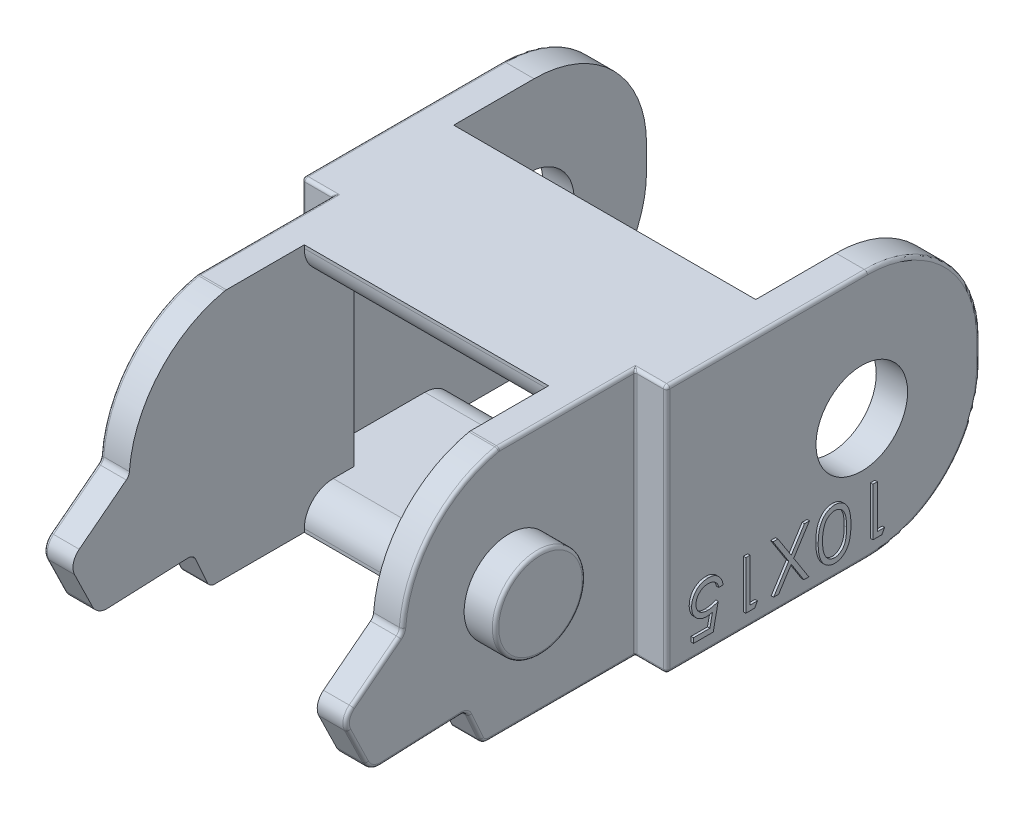
from build123d import *

# Parameters (mm, degrees)
SKETCH1_W               = 38
SKETCH1_H               = 15.5
SKETCH1_R               = 2.85
BOSS_EXTRUDE1_DEPTH     = 11.35
FILLET1_R               = 7
CUT_EXTRUDE1_DEPTH      = 11.35
FILLET2_R               = 1
FILLET3_R               = 0.5
SKETCH4_R               = 2.8
CUT_EXTRUDE2_DEPTH      = 1.95
SKETCH5_W               = 18.8
SKETCH5_H               = 12
SKETCH5_W_2             = 15.2
SKETCH5_H_2             = 14.395243704
CUT_EXTRUDE3_DEPTH      = 8.75
CUT_EXTRUDE3_DEPTH_BACK = 8.75
SKETCH6_W               = 15.2
SKETCH6_H               = 11.5
CUT_EXTRUDE4_DEPTH      = 11.1
CUT_EXTRUDE5_DEPTH      = 11.5
FILLET4_R               = 0.2
BOSS_EXTRUDE2_DEPTH     = 0.15
BOSS_EXTRUDE3_DEPTH     = 0.15
FILLET5_R               = 1.8
FILLET6_R               = 0.2
FILLET7_R               = 0.2
FILLET8_R               = 0.1


with BuildPart() as part:
    # Sketch1 → Boss-Extrude1 (new body, symmetric)
    with BuildSketch(Plane(origin=(0, 0, 0), x_dir=(0, 0, -1), z_dir=(1, 0, 0))):
        with Locations((-11.65, 0)):
            Rectangle(SKETCH1_W, SKETCH1_H)
        Circle(SKETCH1_R, mode=Mode.SUBTRACT)
    extrude(amount=BOSS_EXTRUDE1_DEPTH, both=True)

    # Fillet1
    fillet1_edges = [part.edges().sort_by_distance(p)[0] for p in [
        (0, 7.75, -7.35),
        (0, -7.75, -7.35),
    ]]
    fillet(fillet1_edges, radius=FILLET1_R)

    # Sketch2 → Cut-Extrude1 (cut, symmetric)
    with BuildSketch(Plane(origin=(0, 0, 0), x_dir=(0, 0, -1), z_dir=(1, 0, 0))):
        with BuildLine():
            Line((-26.65, 0.75), (-30.4, -2.153126358))
            Line((-30.4, -2.153126358), (-28.65, -5.75))
            Line((-28.65, -5.75), (-22.655210596, -5.5))
            Line((-22.655210596, -5.5), (-21.65, -7.75))
            Line((-21.65, -7.75), (-30.65, -7.75))
            Line((-30.65, -7.75), (-37.65, -7.75))
            Line((-37.65, -7.75), (-37.65, 7.75))
            Line((-37.65, 7.75), (-30.65, 7.75))
            Line((-30.65, 7.75), (-20.65, 7.75))
            ThreePointArc((-20.65, 7.75), (-24.852601882, 5.280801613), (-26.65, 0.75))
        make_face()
    extrude(amount=CUT_EXTRUDE1_DEPTH, both=True, mode=Mode.SUBTRACT)

    # Fillet2
    fillet2_edges = [part.edges().sort_by_distance(p)[0] for p in [
        (0, -2.153126358, 30.4),
        (0, -5.75, 28.65),
    ]]
    fillet(fillet2_edges, radius=FILLET2_R)

    # Fillet3
    fillet3_edges = [part.edges().sort_by_distance(p)[0] for p in [
        (0, -7.75, 21.65),
        (0, 7.75, 20.65),
        (0, 0.75, 26.65),
        (0, -5.5, 22.655210596),
    ]]
    fillet(fillet3_edges, radius=FILLET3_R)

    # Sketch4 → Cut-Extrude2 (cut)
    with BuildSketch(Plane(origin=(11.35, 0, 0), x_dir=(0, 0, -1), z_dir=(1, 0, 0))):
        with BuildLine():
            Line((-12.15, 7.75), (-12.15, -7.75))
            Line((-12.15, -7.75), (-21.325750072, -7.75))
            ThreePointArc((-21.325750072, -7.75), (-21.597801688, -7.669509139), (-21.78226263, -7.453951671))
            Line((-21.78226263, -7.453951671), (-22.516826691, -5.809749804))
            ThreePointArc((-22.516826691, -5.809749804), (-22.710088376, -5.588614452), (-22.994172583, -5.514135692))
            Line((-22.994172583, -5.514135692), (-27.995644351, -5.722711483))
            ThreePointArc((-27.995644351, -5.722711483), (-28.549859798, -5.582238024), (-28.936529428, -5.161079916))
            Line((-28.936529428, -5.161079916), (-30.044462115, -2.883883414))
            ThreePointArc((-30.044462115, -2.883883414), (-30.119002319, -2.218800109), (-29.757403786, -1.655649556))
            Line((-29.757403786, -1.655649556), (-26.829044364, 0.611389757))
            ThreePointArc((-26.829044364, 0.611389757), (-26.694895774, 0.769693924), (-26.636565214, 0.968826038))
            ThreePointArc((-26.636565214, 0.968826038), (-24.798124082, 5.343650392), (-20.701803833, 7.739295263))
            ThreePointArc((-20.701803833, 7.739295263), (-20.65062725, 7.747316615), (-20.598895402, 7.75))
            Line((-20.598895402, 7.75), (-12.15, 7.75))
        make_face()
        with Locations((-20, 0)):
            Circle(SKETCH4_R, mode=Mode.SUBTRACT)
    cut_extrude2 = extrude(amount=-CUT_EXTRUDE2_DEPTH, mode=Mode.SUBTRACT)

    # Mirror1: Cut-Extrude2 across plane
    add(cut_extrude2.mirror(Plane(origin=(0, 0, 0), x_dir=(0, 0, 1), z_dir=(1, 0, 0))), mode=Mode.SUBTRACT)

    # Sketch5 → Cut-Extrude3 (cut, two sides)
    with BuildSketch(Plane(origin=(0, 0, 0), x_dir=(1, 0, 0), z_dir=(0, 1, 0))) as cut_extrude3_sk:
        with Locations((0, 1.35)):
            Rectangle(SKETCH5_W, SKETCH5_H)
        with Locations((0, -22.947621852)):
            Rectangle(SKETCH5_W_2, SKETCH5_H_2)
    extrude(amount=CUT_EXTRUDE3_DEPTH, mode=Mode.SUBTRACT)
    extrude(cut_extrude3_sk.sketch, amount=-CUT_EXTRUDE3_DEPTH_BACK, mode=Mode.SUBTRACT)

    # Sketch6 → Cut-Extrude4 (cut)
    with BuildSketch(Plane.XY.offset(15.75)):
        Rectangle(SKETCH6_W, SKETCH6_H)
    extrude(amount=-CUT_EXTRUDE4_DEPTH, mode=Mode.SUBTRACT)

    # Sketch7 → Cut-Extrude5 (cut)
    with BuildSketch(Plane(origin=(0, 5.75, 0), x_dir=(1, 0, 0), z_dir=(0, 1, 0))):
        Polygon((-9.4, 7.35), (9.4, 7.35), (9.4, -10.9), (7.6, -12.65), (-7.6, -12.65), (-9.4, -10.9), align=None)
    extrude(amount=-CUT_EXTRUDE5_DEPTH, mode=Mode.SUBTRACT)

    # Fillet4
    fillet4_edges = [part.edges().sort_by_distance(p)[0] for p in [
        (11.35, 0, 22.8),
        (-11.35, 0, 22.8),
    ]]
    fillet(fillet4_edges, radius=FILLET4_R)

    # Sketch8 → Boss-Extrude2 (add)
    with BuildSketch(Plane(origin=(11.35, 0, 0), x_dir=(0, 0, -1), z_dir=(1, 0, 0))):
        Polygon((1.096995192, -6.75), (0.542307692, -6.75), (0.542307692, -3.75), (0.811538462, -3.75), (0.811538462, -6.442307692), (1.273076923, -6.442307692), align=None)
        with BuildLine():
            add(Edge.make_bspline(
                [(-0.826923077, -5.248798077), (-0.827204235, -5.296881552), (-0.82775039, -5.390284396), (-0.833826179, -5.526385517), (-0.843919329, -5.654065766), (-0.857751366, -5.773331248), (-0.874583911, -5.88421277), (-0.897054359, -5.98641396), (-0.922608085, -6.080408008), (-0.952224819, -6.166500859), (-0.985641713, -6.245854324), (-1.022018208, -6.31992902), (-1.062772885, -6.388636459), (-1.105664388, -6.452988962), (-1.152193839, -6.512338906), (-1.202199433, -6.56641956), (-1.255240715, -6.616068984), (-1.311568663, -6.660470758), (-1.3706464, -6.69916098), (-1.43072633, -6.734232792), (-1.493522057, -6.761975563), (-1.557484688, -6.785698827), (-1.623129557, -6.804490859), (-1.69048526, -6.817562192), (-1.759612239, -6.825739896), (-1.806266961, -6.826524941), (-1.829927885, -6.826923077)],
                knots=[0, 0, 0, 0, 0.000144242, 0.000280192, 0.000408604, 0.000528395, 0.000640336, 0.000744892, 0.000842138, 0.000932412, 0.001017795, 0.001100305, 0.00117977, 0.001257276, 0.001332174, 0.00140575, 0.001478035, 0.00154993, 0.001620601, 0.001689774, 0.00175836, 0.001826237, 0.00189434, 0.001962934, 0.002031887, 0.002102841, 0.002102841, 0.002102841, 0.002102841], degree=3))
            add(Edge.make_bspline(
                [(-1.829927885, -6.826923077), (-1.853798437, -6.826592006), (-1.901292435, -6.82593329), (-1.971256848, -6.816661474), (-2.0400026, -6.804694073), (-2.106486682, -6.785500332), (-2.171966181, -6.762532531), (-2.234812753, -6.732226884), (-2.297245215, -6.699267138), (-2.356427342, -6.659059022), (-2.414127389, -6.614622436), (-2.468215159, -6.564175551), (-2.52007328, -6.509114489), (-2.56774309, -6.448211229), (-2.613267652, -6.382399597), (-2.654918808, -6.311127903), (-2.693562824, -6.234554094), (-2.729926107, -6.153033155), (-2.761724837, -6.064387537), (-2.789996451, -5.969170144), (-2.813169822, -5.866518737), (-2.832333792, -5.75700515), (-2.847208681, -5.640086854), (-2.858034374, -5.51600074), (-2.863754811, -5.384669176), (-2.864831892, -5.294876705), (-2.865384615, -5.248798077)],
                knots=[0, 0, 0, 0, 7.1555e-05, 0.000142369, 0.00021144, 0.0002807, 0.000349706, 0.000419339, 0.000489796, 0.0005613, 0.000633668, 0.000708092, 0.000782926, 0.000860357, 0.00093987, 0.00102284, 0.001107769, 0.0011971, 0.001290443, 0.001390083, 0.001494901, 0.001605953, 0.001723504, 0.001848372, 0.00197952, 0.002117762, 0.002117762, 0.002117762, 0.002117762], degree=3))
            add(Edge.make_bspline(
                [(-2.865384615, -5.248798077), (-2.864819043, -5.202921014), (-2.863714583, -5.113331333), (-2.858164563, -4.982582173), (-2.84691848, -4.859173165), (-2.833211538, -4.742925512), (-2.81344881, -4.633991168), (-2.791446988, -4.531785117), (-2.76338243, -4.437267706), (-2.732337958, -4.349381937), (-2.696480646, -4.268206329), (-2.658127665, -4.191948591), (-2.615854752, -4.12108138), (-2.571203723, -4.0548526), (-2.522631428, -3.994471661), (-2.471475102, -3.938794676), (-2.416862597, -3.888260145), (-2.358865525, -3.843298883), (-2.29912402, -3.802787883), (-2.236679388, -3.768652893), (-2.172993398, -3.738894147), (-2.107403637, -3.714971597), (-2.040328349, -3.696060726), (-1.971525986, -3.683187248), (-1.901283078, -3.674113068), (-1.853795307, -3.673423501), (-1.829927885, -3.673076923)],
                knots=[0, 0, 0, 0, 0.000137641, 0.000268789, 0.00039246, 0.000509339, 0.000619799, 0.000724484, 0.000822802, 0.000915375, 0.001003914, 0.001088844, 0.001171296, 0.001251305, 0.001328266, 0.00140354, 0.001477964, 0.001551176, 0.001623514, 0.001694259, 0.001764438, 0.001834214, 0.001903473, 0.001973247, 0.002044061, 0.002115616, 0.002115616, 0.002115616, 0.002115616], degree=3))
            add(Edge.make_bspline(
                [(-1.829927885, -3.673076923), (-1.806267786, -3.673478587), (-1.75961469, -3.67427059), (-1.690475799, -3.682397328), (-1.623217759, -3.6956493), (-1.55770611, -3.713645409), (-1.493806799, -3.736517406), (-1.43214572, -3.765609705), (-1.371908777, -3.799352374), (-1.313369947, -3.837740487), (-1.257648317, -3.88173413), (-1.204411722, -3.930382738), (-1.155053592, -3.984940039), (-1.108845026, -4.044535257), (-1.06559764, -4.109049757), (-1.025015548, -4.178283189), (-0.988749831, -4.253079499), (-0.954575249, -4.33286374), (-0.924450094, -4.419589179), (-0.898145365, -4.51390533), (-0.875968084, -4.616455518), (-0.858303571, -4.727244651), (-0.843832396, -4.84610122), (-0.833836129, -4.97321463), (-0.827753427, -5.108312615), (-0.827204911, -5.20111505), (-0.826923077, -5.248798077)],
                knots=[0, 0, 0, 0, 7.0954e-05, 0.000139908, 0.000208502, 0.000276442, 0.000343548, 0.000411839, 0.000480717, 0.000550555, 0.000621606, 0.000693483, 0.000766652, 0.000842024, 0.00091953, 0.000999514, 0.001082562, 0.001168733, 0.001259772, 0.001357758, 0.001462313, 0.00157435, 0.001694212, 0.001821425, 0.001956775, 0.002099815, 0.002099815, 0.002099815, 0.002099815], degree=3))
        make_face()
        with BuildLine():
            add(Edge.make_bspline(
                [(-1.096153846, -5.25), (-1.096258474, -5.209929847), (-1.096461537, -5.132161548), (-1.101612887, -5.019350556), (-1.108783039, -4.913954956), (-1.117803506, -4.816015885), (-1.131312927, -4.725875627), (-1.146640227, -4.643159475), (-1.165024268, -4.568020402), (-1.186883537, -4.499802223), (-1.211782057, -4.437537456), (-1.238923651, -4.379571665), (-1.268323864, -4.325199782), (-1.300657224, -4.274617982), (-1.336386975, -4.228108775), (-1.374715617, -4.185451275), (-1.415866019, -4.14681917), (-1.472818093, -4.10097069), (-1.547639688, -4.053034453), (-1.642393756, -4.011804733), (-1.73980075, -3.98572701), (-1.805933435, -3.982419908), (-1.838942308, -3.980769231)],
                knots=[0, 0, 0, 0, 0.000120198, 0.000233281, 0.000338697, 0.000437124, 0.000528233, 0.000612034, 0.00068943, 0.000760129, 0.000826752, 0.000890468, 0.000952051, 0.001012063, 0.001070359, 0.001127804, 0.001183922, 0.001239484, 0.001347016, 0.001449286, 0.001548546, 0.001647462, 0.001647462, 0.001647462, 0.001647462], degree=3))
            add(Edge.make_bspline(
                [(-1.838942308, -3.980769231), (-1.872140723, -3.982216648), (-1.938419793, -3.985106349), (-2.035760485, -4.010326521), (-2.129477473, -4.051326511), (-2.203437927, -4.098168028), (-2.259549583, -4.143062336), (-2.299767493, -4.181294919), (-2.33667689, -4.224116609), (-2.371684641, -4.270315345), (-2.403792349, -4.320777658), (-2.432989344, -4.375259813), (-2.459632208, -4.433913409), (-2.474811391, -4.474858898), (-2.482572115, -4.495793269)],
                knots=[0, 0, 0, 0, 9.9466e-05, 0.000198579, 0.000299507, 0.00040538, 0.000460097, 0.00051493, 0.000571577, 0.000629509, 0.000688691, 0.000750803, 0.000814813, 0.000881776, 0.000881776, 0.000881776, 0.000881776], degree=3))
            add(Edge.make_bspline(
                [(-2.482572115, -4.495793269), (-2.491616488, -4.522561617), (-2.509980442, -4.576912844), (-2.533647678, -4.661224546), (-2.552286591, -4.749684058), (-2.56905519, -4.841762729), (-2.580500667, -4.938139616), (-2.589713078, -5.038516516), (-2.595139381, -5.142969112), (-2.595812025, -5.213936248), (-2.596153846, -5.25)],
                knots=[0, 0, 0, 0, 8.4759e-05, 0.000172097, 0.000262507, 0.000355875, 0.000452777, 0.000553542, 0.000658249, 0.000766437, 0.000766437, 0.000766437, 0.000766437], degree=3))
            add(Edge.make_bspline(
                [(-2.596153846, -5.25), (-2.595776854, -5.286062977), (-2.595039286, -5.356618597), (-2.590193396, -5.459841532), (-2.582406454, -5.558052396), (-2.571866998, -5.651340283), (-2.557398556, -5.739539155), (-2.540023389, -5.82277521), (-2.51965303, -5.90102605), (-2.496287513, -5.974493337), (-2.469955274, -6.042913495), (-2.440864751, -6.106433808), (-2.4098257, -6.165396873), (-2.376090597, -6.219613037), (-2.340136736, -6.269398656), (-2.300673142, -6.313607695), (-2.26020651, -6.354390801), (-2.202654395, -6.400111668), (-2.127921234, -6.447097407), (-2.034286469, -6.489160312), (-1.937378525, -6.514054274), (-1.871730722, -6.517506515), (-1.838942308, -6.519230769)],
                knots=[0, 0, 0, 0, 0.000108188, 0.000211665, 0.000309933, 0.000403708, 0.000493219, 0.000577963, 0.000658716, 0.000735688, 0.000809124, 0.000878505, 0.000945177, 0.001008879, 0.001069941, 0.001129132, 0.001186501, 0.001242063, 0.001349274, 0.001450442, 0.001548973, 0.00164729, 0.00164729, 0.00164729, 0.00164729], degree=3))
            add(Edge.make_bspline(
                [(-1.838942308, -6.519230769), (-1.805755365, -6.517504475), (-1.73932102, -6.51404874), (-1.641399308, -6.489248142), (-1.547204004, -6.447396572), (-1.47262833, -6.400053566), (-1.415886432, -6.354568361), (-1.375507884, -6.315747701), (-1.337401073, -6.273489137), (-1.301842487, -6.227190805), (-1.269706403, -6.176705455), (-1.239948857, -6.122727737), (-1.213023806, -6.064848052), (-1.188031304, -6.002617698), (-1.166403974, -5.934287424), (-1.146958483, -5.859163336), (-1.13194949, -5.775909245), (-1.118622823, -5.685345688), (-1.108549378, -5.587290175), (-1.101662859, -5.481645078), (-1.096445891, -5.368440834), (-1.096253144, -5.290271014), (-1.096153846, -5.25)],
                knots=[0, 0, 0, 0, 9.9515e-05, 0.000199211, 0.00030093, 0.000407632, 0.000463195, 0.000518877, 0.000575473, 0.000633769, 0.000693781, 0.000754837, 0.000818553, 0.000885176, 0.000955875, 0.001033418, 0.00111781, 0.001209513, 0.001308001, 0.001413416, 0.001527099, 0.001647899, 0.001647899, 0.001647899, 0.001647899], degree=3))
        make_face(mode=Mode.SUBTRACT)
        Polygon((-3.446153846, -6.75), (-3.756850962, -6.75), (-4.542307692, -5.522836538), (-5.327764423, -6.75), (-5.638461538, -6.75), (-4.697956731, -5.280048077), (-5.676923077, -3.75), (-5.366225962, -3.75), (-4.542307692, -5.037259615), (-3.718389423, -3.75), (-3.407692308, -3.75), (-4.387259615, -5.280048077), align=None)
        Polygon((-6.818389423, -6.75), (-7.373076923, -6.75), (-7.373076923, -3.75), (-7.103846154, -3.75), (-7.103846154, -6.442307692), (-6.642307692, -6.442307692), align=None)
        with BuildLine():
            Line((-10.626923077, -6.75), (-10.626923077, -6.442307692))
            Line((-10.626923077, -6.442307692), (-9.606490385, -6.442307692))
            Line((-9.606490385, -6.442307692), (-9.444831731, -5.653245192))
            add(Edge.make_bspline(
                [(-9.444831731, -5.653245192), (-9.476593909, -5.662013997), (-9.538128105, -5.679002168), (-9.628950843, -5.697864257), (-9.715172732, -5.709234638), (-9.771123049, -5.71078719), (-9.798197115, -5.711538462)],
                knots=[0, 0, 0, 0, 9.883e-05, 0.000191468, 0.000278084, 0.000359294, 0.000359294, 0.000359294, 0.000359294], degree=3))
            add(Edge.make_bspline(
                [(-9.798197115, -5.711538462), (-9.831703497, -5.71083713), (-9.897585416, -5.709458136), (-9.99383075, -5.695436982), (-10.086162499, -5.675114767), (-10.173252595, -5.643855323), (-10.256505108, -5.605435944), (-10.334791341, -5.557673963), (-10.408479032, -5.501249964), (-10.477407112, -5.437321415), (-10.539548196, -5.366143978), (-10.593762955, -5.289550699), (-10.640103573, -5.208396244), (-10.677069662, -5.12193413), (-10.707041078, -5.03097917), (-10.726858212, -4.934768153), (-10.74008012, -4.834101561), (-10.741555396, -4.765268624), (-10.742307692, -4.730168269)],
                knots=[0, 0, 0, 0, 0.000100449, 0.000197507, 0.000291244, 0.000383616, 0.000474489, 0.000565908, 0.000658098, 0.000752497, 0.000847474, 0.000941017, 0.001033597, 0.001127264, 0.001222667, 0.00132038, 0.001421531, 0.001526784, 0.001526784, 0.001526784, 0.001526784], degree=3))
            add(Edge.make_bspline(
                [(-10.742307692, -4.730168269), (-10.741737191, -4.705720772), (-10.740603898, -4.657156166), (-10.734851512, -4.585030796), (-10.723739936, -4.514440663), (-10.708981563, -4.44552559), (-10.689357088, -4.378182732), (-10.666150174, -4.312253197), (-10.638373062, -4.247846059), (-10.606675576, -4.185281802), (-10.57061215, -4.125791849), (-10.53212437, -4.068683016), (-10.490186047, -4.015612086), (-10.445531342, -3.965691971), (-10.397302841, -3.920358462), (-10.346684074, -3.87772045), (-10.292543107, -3.839586497), (-10.2358344, -3.804514204), (-10.176597735, -3.773111217), (-10.114231376, -3.746915675), (-10.050104721, -3.723955012), (-9.983646134, -3.70528329), (-9.91498439, -3.69079673), (-9.843883039, -3.68093158), (-9.770698858, -3.673753825), (-9.721091807, -3.673304096), (-9.696033654, -3.673076923)],
                knots=[0, 0, 0, 0, 7.3357e-05, 0.000145722, 0.000216862, 0.000287587, 0.00035701, 0.000427148, 0.000497141, 0.000567289, 0.000637372, 0.000705713, 0.00077376, 0.000840138, 0.000906451, 0.000972163, 0.00103853, 0.001104908, 0.001172111, 0.001239422, 0.001307659, 0.00137634, 0.001446352, 0.001517997, 0.001591612, 0.001666754, 0.001666754, 0.001666754, 0.001666754], degree=3))
            add(Edge.make_bspline(
                [(-9.696033654, -3.673076923), (-9.666142298, -3.673670715), (-9.607334588, -3.674838929), (-9.521162706, -3.687002757), (-9.438306088, -3.704543161), (-9.359108382, -3.730516271), (-9.283942028, -3.764575823), (-9.211716666, -3.804783406), (-9.143754379, -3.853312366), (-9.079573007, -3.908422962), (-9.020697431, -3.969547522), (-8.96649583, -4.034532125), (-8.919564034, -4.10481811), (-8.878784933, -4.17923288), (-8.844095099, -4.257970436), (-8.816818832, -4.341213533), (-8.794810534, -4.428557815), (-8.785498794, -4.4886892), (-8.780769231, -4.519230769)],
                knots=[0, 0, 0, 0, 8.9616e-05, 0.000176309, 0.000260591, 0.00034345, 0.000425764, 0.000507834, 0.000591039, 0.000675842, 0.000761266, 0.000845368, 0.000929374, 0.001014363, 0.001099667, 0.001187086, 0.001276871, 0.001369544, 0.001369544, 0.001369544, 0.001369544], degree=3))
            Line((-8.780769231, -4.519230769), (-9.05, -4.519230769))
            add(Edge.make_bspline(
                [(-9.05, -4.519230769), (-9.056616161, -4.49061664), (-9.069332788, -4.435618694), (-9.097391256, -4.358439665), (-9.131154861, -4.289377805), (-9.173164878, -4.228867426), (-9.220883758, -4.174871741), (-9.27595907, -4.126854836), (-9.337922787, -4.084057627), (-9.40678875, -4.048092554), (-9.479627635, -4.017841582), (-9.555416432, -3.996242714), (-9.633078969, -3.983170993), (-9.685366843, -3.981572831), (-9.711658654, -3.980769231)],
                knots=[0, 0, 0, 0, 8.8036e-05, 0.000169211, 0.000245807, 0.000317985, 0.000389502, 0.000461469, 0.000536649, 0.000614881, 0.000694116, 0.000772868, 0.000850819, 0.000929657, 0.000929657, 0.000929657, 0.000929657], degree=3))
            add(Edge.make_bspline(
                [(-9.711658654, -3.980769231), (-9.737335142, -3.981478641), (-9.787892358, -3.982875476), (-9.862333362, -3.993453055), (-9.933993294, -4.01017165), (-10.00299936, -4.033593445), (-10.069012476, -4.064579107), (-10.131939307, -4.102643206), (-10.192676301, -4.146836079), (-10.249624952, -4.197346919), (-10.301770302, -4.253041508), (-10.347847696, -4.312591918), (-10.386227719, -4.376121074), (-10.418571291, -4.442526519), (-10.443131248, -4.512536742), (-10.460652093, -4.585823455), (-10.470940428, -4.662567726), (-10.472355725, -4.714912849), (-10.473076923, -4.741586538)],
                knots=[0, 0, 0, 0, 7.7008e-05, 0.000151628, 0.000225096, 0.000297504, 0.000369824, 0.000443412, 0.000517817, 0.000594874, 0.000671406, 0.000746411, 0.00082031, 0.000893689, 0.000967626, 0.001042402, 0.001119405, 0.001199414, 0.001199414, 0.001199414, 0.001199414], degree=3))
            add(Edge.make_bspline(
                [(-10.473076923, -4.741586538), (-10.472621074, -4.765668908), (-10.471732061, -4.812635185), (-10.461218344, -4.881284613), (-10.447057194, -4.946814275), (-10.42472251, -5.008611904), (-10.397593881, -5.067322665), (-10.362246399, -5.121495885), (-10.323167464, -5.173780416), (-10.276367771, -5.220719639), (-10.225694486, -5.264404384), (-10.169539338, -5.30145519), (-10.109507126, -5.332978528), (-10.045457946, -5.358802472), (-9.977320699, -5.379374267), (-9.905056524, -5.39359145), (-9.828649558, -5.402098865), (-9.776384716, -5.403252933), (-9.749519231, -5.403846154)],
                knots=[0, 0, 0, 0, 7.2178e-05, 0.000140764, 0.00020797, 0.000272974, 0.00033749, 0.000401511, 0.000466659, 0.000532956, 0.0005999, 0.000667071, 0.000734274, 0.000803018, 0.000873934, 0.000947477, 0.001023665, 0.00110425, 0.00110425, 0.00110425, 0.00110425], degree=3))
            add(Edge.make_bspline(
                [(-9.749519231, -5.403846154), (-9.726063925, -5.403365403), (-9.678047274, -5.402381232), (-9.604221755, -5.394636009), (-9.526979812, -5.382720729), (-9.446021567, -5.365547008), (-9.361569198, -5.344044327), (-9.273482257, -5.317190174), (-9.181758617, -5.286257576), (-9.12002204, -5.262265199), (-9.088461538, -5.25)],
                knots=[0, 0, 0, 0, 7.0354e-05, 0.000144025, 0.000222475, 0.000304743, 0.000392197, 0.000483835, 0.000580948, 0.000682515, 0.000682515, 0.000682515, 0.000682515], degree=3))
            Line((-9.088461538, -5.25), (-9.396153846, -6.75))
            Line((-9.396153846, -6.75), (-10.626923077, -6.75))
        make_face()
    extrude(amount=BOSS_EXTRUDE2_DEPTH)

    # Sketch9 → Boss-Extrude3 (add)
    with BuildSketch(Plane.ZY.offset(11.35)):
        Polygon((10.396995192, -6.75), (9.842307692, -6.75), (9.842307692, -3.75), (10.111538462, -3.75), (10.111538462, -6.442307692), (10.573076923, -6.442307692), align=None)
        with BuildLine():
            add(Edge.make_bspline(
                [(8.6, -5.248798077), (8.599718842, -5.296881552), (8.599172687, -5.390284396), (8.593096898, -5.526385517), (8.583003748, -5.654065766), (8.569171711, -5.773331248), (8.552339166, -5.88421277), (8.529868718, -5.98641396), (8.504314992, -6.080408008), (8.474698258, -6.166500859), (8.441281364, -6.245854324), (8.404904869, -6.31992902), (8.364150192, -6.388636459), (8.321258689, -6.452988962), (8.274729238, -6.512338906), (8.224723644, -6.56641956), (8.171682362, -6.616068984), (8.115354414, -6.660470758), (8.056276677, -6.69916098), (7.996196747, -6.734232792), (7.93340102, -6.761975563), (7.869438389, -6.785698827), (7.80379352, -6.804490859), (7.736437817, -6.817562192), (7.667310838, -6.825739896), (7.620656116, -6.826524941), (7.596995192, -6.826923077)],
                knots=[0, 0, 0, 0, 0.000144242, 0.000280192, 0.000408604, 0.000528395, 0.000640336, 0.000744892, 0.000842138, 0.000932412, 0.001017795, 0.001100305, 0.00117977, 0.001257276, 0.001332174, 0.00140575, 0.001478035, 0.00154993, 0.001620601, 0.001689774, 0.00175836, 0.001826237, 0.00189434, 0.001962934, 0.002031887, 0.002102841, 0.002102841, 0.002102841, 0.002102841], degree=3))
            add(Edge.make_bspline(
                [(7.596995192, -6.826923077), (7.57312464, -6.826592006), (7.525630642, -6.82593329), (7.455666229, -6.816661474), (7.386920477, -6.804694073), (7.320436395, -6.785500332), (7.254956896, -6.762532531), (7.192110324, -6.732226884), (7.129677862, -6.699267138), (7.070495735, -6.659059022), (7.012795688, -6.614622436), (6.958707918, -6.564175551), (6.906849797, -6.509114489), (6.859179987, -6.448211229), (6.813655425, -6.382399597), (6.772004269, -6.311127903), (6.733360253, -6.234554094), (6.69699697, -6.153033155), (6.665198239, -6.064387537), (6.636926626, -5.969170144), (6.613753255, -5.866518737), (6.594589285, -5.75700515), (6.579714396, -5.640086854), (6.568888703, -5.51600074), (6.563168266, -5.384669176), (6.562091185, -5.294876705), (6.561538462, -5.248798077)],
                knots=[0, 0, 0, 0, 7.1555e-05, 0.000142369, 0.00021144, 0.0002807, 0.000349706, 0.000419339, 0.000489796, 0.0005613, 0.000633668, 0.000708092, 0.000782926, 0.000860357, 0.00093987, 0.00102284, 0.001107769, 0.0011971, 0.001290443, 0.001390083, 0.001494901, 0.001605953, 0.001723504, 0.001848372, 0.00197952, 0.002117762, 0.002117762, 0.002117762, 0.002117762], degree=3))
            add(Edge.make_bspline(
                [(6.561538462, -5.248798077), (6.562104033, -5.202921014), (6.563208494, -5.113331333), (6.568758514, -4.982582173), (6.580004597, -4.859173165), (6.593711539, -4.742925512), (6.613474267, -4.633991168), (6.635476089, -4.531785117), (6.663540647, -4.437267706), (6.694585119, -4.349381937), (6.730442431, -4.268206329), (6.768795412, -4.191948591), (6.811068325, -4.12108138), (6.855719354, -4.0548526), (6.904291649, -3.994471661), (6.955447975, -3.938794676), (7.01006048, -3.888260145), (7.068057552, -3.843298883), (7.127799057, -3.802787883), (7.190243689, -3.768652893), (7.253929678, -3.738894147), (7.31951944, -3.714971597), (7.386594728, -3.696060726), (7.455397091, -3.683187248), (7.525639999, -3.674113068), (7.57312777, -3.673423501), (7.596995192, -3.673076923)],
                knots=[0, 0, 0, 0, 0.000137641, 0.000268789, 0.00039246, 0.000509339, 0.000619799, 0.000724484, 0.000822802, 0.000915375, 0.001003914, 0.001088844, 0.001171296, 0.001251305, 0.001328266, 0.00140354, 0.001477964, 0.001551176, 0.001623514, 0.001694259, 0.001764438, 0.001834214, 0.001903473, 0.001973247, 0.002044061, 0.002115616, 0.002115616, 0.002115616, 0.002115616], degree=3))
            add(Edge.make_bspline(
                [(7.596995192, -3.673076923), (7.620655291, -3.673478587), (7.667308387, -3.67427059), (7.736447278, -3.682397328), (7.803705318, -3.6956493), (7.869216967, -3.713645409), (7.933116278, -3.736517406), (7.994777357, -3.765609705), (8.0550143, -3.799352374), (8.11355313, -3.837740487), (8.16927476, -3.88173413), (8.222511355, -3.930382738), (8.271869485, -3.984940039), (8.318078051, -4.044535257), (8.361325437, -4.109049757), (8.401907529, -4.178283189), (8.438173246, -4.253079499), (8.472347828, -4.33286374), (8.502472983, -4.419589179), (8.528777712, -4.51390533), (8.550954992, -4.616455518), (8.568619506, -4.727244651), (8.583090681, -4.84610122), (8.593086948, -4.97321463), (8.59916965, -5.108312615), (8.599718166, -5.20111505), (8.6, -5.248798077)],
                knots=[0, 0, 0, 0, 7.0954e-05, 0.000139908, 0.000208502, 0.000276442, 0.000343548, 0.000411839, 0.000480717, 0.000550555, 0.000621606, 0.000693483, 0.000766652, 0.000842024, 0.00091953, 0.000999514, 0.001082562, 0.001168733, 0.001259772, 0.001357758, 0.001462313, 0.00157435, 0.001694212, 0.001821425, 0.001956775, 0.002099815, 0.002099815, 0.002099815, 0.002099815], degree=3))
        make_face()
        with BuildLine():
            add(Edge.make_bspline(
                [(8.330769231, -5.25), (8.330664603, -5.209929847), (8.33046154, -5.132161548), (8.32531019, -5.019350556), (8.318140038, -4.913954956), (8.309119571, -4.816015885), (8.29561015, -4.725875627), (8.28028285, -4.643159475), (8.261898809, -4.568020402), (8.24003954, -4.499802223), (8.21514102, -4.437537456), (8.187999426, -4.379571665), (8.158599213, -4.325199782), (8.126265853, -4.274617982), (8.090536102, -4.228108775), (8.05220746, -4.185451275), (8.011057058, -4.14681917), (7.954104984, -4.10097069), (7.879283389, -4.053034453), (7.784529321, -4.011804733), (7.687122327, -3.98572701), (7.620989642, -3.982419908), (7.587980769, -3.980769231)],
                knots=[0, 0, 0, 0, 0.000120198, 0.000233281, 0.000338697, 0.000437124, 0.000528233, 0.000612034, 0.00068943, 0.000760129, 0.000826752, 0.000890468, 0.000952051, 0.001012063, 0.001070359, 0.001127804, 0.001183922, 0.001239484, 0.001347016, 0.001449286, 0.001548546, 0.001647462, 0.001647462, 0.001647462, 0.001647462], degree=3))
            add(Edge.make_bspline(
                [(7.587980769, -3.980769231), (7.554782354, -3.982216648), (7.488503284, -3.985106349), (7.391162592, -4.010326521), (7.297445604, -4.051326511), (7.22348515, -4.098168028), (7.167373494, -4.143062336), (7.127155584, -4.181294919), (7.090246187, -4.224116609), (7.055238436, -4.270315345), (7.023130728, -4.320777658), (6.993933733, -4.375259813), (6.967290869, -4.433913409), (6.952111686, -4.474858898), (6.944350962, -4.495793269)],
                knots=[0, 0, 0, 0, 9.9466e-05, 0.000198579, 0.000299507, 0.00040538, 0.000460097, 0.00051493, 0.000571577, 0.000629509, 0.000688691, 0.000750803, 0.000814813, 0.000881776, 0.000881776, 0.000881776, 0.000881776], degree=3))
            add(Edge.make_bspline(
                [(6.944350962, -4.495793269), (6.935306589, -4.522561617), (6.916942634, -4.576912844), (6.893275399, -4.661224546), (6.874636486, -4.749684058), (6.857867887, -4.841762729), (6.84642241, -4.938139616), (6.837209999, -5.038516516), (6.831783696, -5.142969112), (6.831111052, -5.213936248), (6.830769231, -5.25)],
                knots=[0, 0, 0, 0, 8.4759e-05, 0.000172097, 0.000262507, 0.000355875, 0.000452777, 0.000553542, 0.000658249, 0.000766437, 0.000766437, 0.000766437, 0.000766437], degree=3))
            add(Edge.make_bspline(
                [(6.830769231, -5.25), (6.831146223, -5.286062977), (6.831883791, -5.356618597), (6.836729681, -5.459841532), (6.844516623, -5.558052396), (6.855056079, -5.651340283), (6.869524521, -5.739539155), (6.886899688, -5.82277521), (6.907270047, -5.90102605), (6.930635564, -5.974493337), (6.956967803, -6.042913495), (6.986058326, -6.106433808), (7.017097377, -6.165396873), (7.05083248, -6.219613037), (7.08678634, -6.269398656), (7.126249935, -6.313607695), (7.166716567, -6.354390801), (7.224268682, -6.400111668), (7.299001843, -6.447097407), (7.392636608, -6.489160312), (7.489544552, -6.514054274), (7.555192355, -6.517506515), (7.587980769, -6.519230769)],
                knots=[0, 0, 0, 0, 0.000108188, 0.000211665, 0.000309933, 0.000403708, 0.000493219, 0.000577963, 0.000658716, 0.000735688, 0.000809124, 0.000878505, 0.000945177, 0.001008879, 0.001069941, 0.001129132, 0.001186501, 0.001242063, 0.001349274, 0.001450442, 0.001548973, 0.00164729, 0.00164729, 0.00164729, 0.00164729], degree=3))
            add(Edge.make_bspline(
                [(7.587980769, -6.519230769), (7.621167712, -6.517504475), (7.687602057, -6.51404874), (7.785523768, -6.489248142), (7.879719073, -6.447396572), (7.954294747, -6.400053566), (8.011036645, -6.354568361), (8.051415193, -6.315747701), (8.089522004, -6.273489137), (8.12508059, -6.227190805), (8.157216674, -6.176705455), (8.18697422, -6.122727737), (8.213899271, -6.064848052), (8.238891773, -6.002617698), (8.260519103, -5.934287424), (8.279964594, -5.859163336), (8.294973587, -5.775909245), (8.308300254, -5.685345688), (8.318373699, -5.587290175), (8.325260218, -5.481645078), (8.330477186, -5.368440834), (8.330669933, -5.290271014), (8.330769231, -5.25)],
                knots=[0, 0, 0, 0, 9.9515e-05, 0.000199211, 0.00030093, 0.000407632, 0.000463195, 0.000518877, 0.000575473, 0.000633769, 0.000693781, 0.000754837, 0.000818553, 0.000885176, 0.000955875, 0.001033418, 0.00111781, 0.001209513, 0.001308001, 0.001413416, 0.001527099, 0.001647899, 0.001647899, 0.001647899, 0.001647899], degree=3))
        make_face(mode=Mode.SUBTRACT)
        Polygon((6.107692308, -6.75), (5.796995192, -6.75), (5.011538462, -5.522836538), (4.226081731, -6.75), (3.915384615, -6.75), (4.855889423, -5.280048077), (3.876923077, -3.75), (4.187620192, -3.75), (5.011538462, -5.037259615), (5.835456731, -3.75), (6.146153846, -3.75), (5.166586538, -5.280048077), align=None)
        Polygon((2.862379808, -6.75), (2.307692308, -6.75), (2.307692308, -3.75), (2.576923077, -3.75), (2.576923077, -6.442307692), (3.038461538, -6.442307692), align=None)
        with BuildLine():
            Line((-0.819230769, -6.75), (-0.819230769, -6.442307692))
            Line((-0.819230769, -6.442307692), (0.201201923, -6.442307692))
            Line((0.201201923, -6.442307692), (0.362860577, -5.653245192))
            add(Edge.make_bspline(
                [(0.362860577, -5.653245192), (0.331098399, -5.662013997), (0.269564202, -5.679002168), (0.178741464, -5.697864257), (0.092519576, -5.709234638), (0.036569258, -5.71078719), (0.009495192, -5.711538462)],
                knots=[0, 0, 0, 0, 9.883e-05, 0.000191468, 0.000278084, 0.000359294, 0.000359294, 0.000359294, 0.000359294], degree=3))
            add(Edge.make_bspline(
                [(0.009495192, -5.711538462), (-0.02401119, -5.71083713), (-0.089893108, -5.709458136), (-0.186138442, -5.695436982), (-0.278470191, -5.675114767), (-0.365560287, -5.643855323), (-0.448812801, -5.605435944), (-0.527099034, -5.557673963), (-0.600786725, -5.501249964), (-0.669714804, -5.437321415), (-0.731855888, -5.366143978), (-0.786070647, -5.289550699), (-0.832411266, -5.208396244), (-0.869377354, -5.12193413), (-0.89934877, -5.03097917), (-0.919165904, -4.934768153), (-0.932387812, -4.834101561), (-0.933863089, -4.765268624), (-0.934615385, -4.730168269)],
                knots=[0, 0, 0, 0, 0.000100449, 0.000197507, 0.000291244, 0.000383616, 0.000474489, 0.000565908, 0.000658098, 0.000752497, 0.000847474, 0.000941017, 0.001033597, 0.001127264, 0.001222667, 0.00132038, 0.001421531, 0.001526784, 0.001526784, 0.001526784, 0.001526784], degree=3))
            add(Edge.make_bspline(
                [(-0.934615385, -4.730168269), (-0.934044883, -4.705720772), (-0.932911591, -4.657156166), (-0.927159204, -4.585030796), (-0.916047628, -4.514440663), (-0.901289255, -4.44552559), (-0.881664781, -4.378182732), (-0.858457866, -4.312253197), (-0.830680754, -4.247846059), (-0.798983268, -4.185281802), (-0.762919842, -4.125791849), (-0.724432062, -4.068683016), (-0.68249374, -4.015612086), (-0.637839034, -3.965691971), (-0.589610533, -3.920358462), (-0.538991767, -3.87772045), (-0.484850799, -3.839586497), (-0.428142093, -3.804514204), (-0.368905428, -3.773111217), (-0.306539068, -3.746915675), (-0.242412413, -3.723955012), (-0.175953827, -3.70528329), (-0.107292082, -3.69079673), (-0.036190732, -3.68093158), (0.03699345, -3.673753825), (0.086600501, -3.673304096), (0.111658654, -3.673076923)],
                knots=[0, 0, 0, 0, 7.3357e-05, 0.000145722, 0.000216862, 0.000287587, 0.00035701, 0.000427148, 0.000497141, 0.000567289, 0.000637372, 0.000705713, 0.00077376, 0.000840138, 0.000906451, 0.000972163, 0.00103853, 0.001104908, 0.001172111, 0.001239422, 0.001307659, 0.00137634, 0.001446352, 0.001517997, 0.001591612, 0.001666754, 0.001666754, 0.001666754, 0.001666754], degree=3))
            add(Edge.make_bspline(
                [(0.111658654, -3.673076923), (0.141550009, -3.673670715), (0.20035772, -3.674838929), (0.286529602, -3.687002757), (0.369386219, -3.704543161), (0.448583926, -3.730516271), (0.52375028, -3.764575823), (0.595975641, -3.804783406), (0.663937929, -3.853312366), (0.728119301, -3.908422962), (0.786994877, -3.969547522), (0.841196478, -4.034532125), (0.888128273, -4.10481811), (0.928907375, -4.17923288), (0.963597209, -4.257970436), (0.990873475, -4.341213533), (1.012881774, -4.428557815), (1.022193514, -4.4886892), (1.026923077, -4.519230769)],
                knots=[0, 0, 0, 0, 8.9616e-05, 0.000176309, 0.000260591, 0.00034345, 0.000425764, 0.000507834, 0.000591039, 0.000675842, 0.000761266, 0.000845368, 0.000929374, 0.001014363, 0.001099667, 0.001187086, 0.001276871, 0.001369544, 0.001369544, 0.001369544, 0.001369544], degree=3))
            Line((1.026923077, -4.519230769), (0.757692308, -4.519230769))
            add(Edge.make_bspline(
                [(0.757692308, -4.519230769), (0.751076147, -4.49061664), (0.738359519, -4.435618694), (0.710301052, -4.358439665), (0.676537446, -4.289377805), (0.634527429, -4.228867426), (0.58680855, -4.174871741), (0.531733238, -4.126854836), (0.469769521, -4.084057627), (0.400903558, -4.048092554), (0.328064672, -4.017841582), (0.252275876, -3.996242714), (0.174613339, -3.983170993), (0.122325465, -3.981572831), (0.096033654, -3.980769231)],
                knots=[0, 0, 0, 0, 8.8036e-05, 0.000169211, 0.000245807, 0.000317985, 0.000389502, 0.000461469, 0.000536649, 0.000614881, 0.000694116, 0.000772868, 0.000850819, 0.000929657, 0.000929657, 0.000929657, 0.000929657], degree=3))
            add(Edge.make_bspline(
                [(0.096033654, -3.980769231), (0.070357166, -3.981478641), (0.01979995, -3.982875476), (-0.054641055, -3.993453055), (-0.126300987, -4.01017165), (-0.195307052, -4.033593445), (-0.261320168, -4.064579107), (-0.324246999, -4.102643206), (-0.384983993, -4.146836079), (-0.441932644, -4.197346919), (-0.494077994, -4.253041508), (-0.540155388, -4.312591918), (-0.578535411, -4.376121074), (-0.610878983, -4.442526519), (-0.63543894, -4.512536742), (-0.652959785, -4.585823455), (-0.66324812, -4.662567726), (-0.664663417, -4.714912849), (-0.665384615, -4.741586538)],
                knots=[0, 0, 0, 0, 7.7008e-05, 0.000151628, 0.000225096, 0.000297504, 0.000369824, 0.000443412, 0.000517817, 0.000594874, 0.000671406, 0.000746411, 0.00082031, 0.000893689, 0.000967626, 0.001042402, 0.001119405, 0.001199414, 0.001199414, 0.001199414, 0.001199414], degree=3))
            add(Edge.make_bspline(
                [(-0.665384615, -4.741586538), (-0.664928766, -4.765668908), (-0.664039754, -4.812635185), (-0.653526036, -4.881284613), (-0.639364886, -4.946814275), (-0.617030203, -5.008611904), (-0.589901573, -5.067322665), (-0.554554092, -5.121495885), (-0.515475156, -5.173780416), (-0.468675463, -5.220719639), (-0.418002178, -5.264404384), (-0.361847031, -5.30145519), (-0.301814819, -5.332978528), (-0.237765638, -5.358802472), (-0.169628392, -5.379374267), (-0.097364216, -5.39359145), (-0.02095725, -5.402098865), (0.031307592, -5.403252933), (0.058173077, -5.403846154)],
                knots=[0, 0, 0, 0, 7.2178e-05, 0.000140764, 0.00020797, 0.000272974, 0.00033749, 0.000401511, 0.000466659, 0.000532956, 0.0005999, 0.000667071, 0.000734274, 0.000803018, 0.000873934, 0.000947477, 0.001023665, 0.00110425, 0.00110425, 0.00110425, 0.00110425], degree=3))
            add(Edge.make_bspline(
                [(0.058173077, -5.403846154), (0.081628382, -5.403365403), (0.129645034, -5.402381232), (0.203470553, -5.394636009), (0.280712496, -5.382720729), (0.36167074, -5.365547008), (0.44612311, -5.344044327), (0.534210051, -5.317190174), (0.62593369, -5.286257576), (0.687670268, -5.262265199), (0.719230769, -5.25)],
                knots=[0, 0, 0, 0, 7.0354e-05, 0.000144025, 0.000222475, 0.000304743, 0.000392197, 0.000483835, 0.000580948, 0.000682515, 0.000682515, 0.000682515, 0.000682515], degree=3))
            Line((0.719230769, -5.25), (0.411538462, -6.75))
            Line((0.411538462, -6.75), (-0.819230769, -6.75))
        make_face()
    extrude(amount=BOSS_EXTRUDE3_DEPTH)

    # Fillet5
    fillet5_edges = [part.edges().sort_by_distance(p)[0] for p in [
        (0, 5.75, 15.75),
        (0, -5.75, 15.75),
        (0, -5.75, 4.65),
        (0, 5.75, 4.65),
    ]]
    fillet(fillet5_edges, radius=FILLET5_R)

    # Fillet6
    fillet6_edges = [part.edges().sort_by_distance(p)[0] for p in [
        (11.35, -7.75, 5.9),
        (9.4, 7.747316615, 20.65062725),
        (9.4, 7.75, 16.374447701),
        (9.4, -7.75, 16.737875036),
        (9.4, -7.669509139, 21.597801688),
        (9.4, -6.631850738, 22.14954466),
        (9.4, -5.588614452, 22.710088376),
        (9.4, -5.618423588, 25.494908467),
        (9.4, -5.582238024, 28.549859798),
        (9.4, -4.022481665, 29.490495771),
        (9.4, -2.218800109, 30.119002319),
        (9.4, -0.522129899, 28.293224075),
        (9.4, 0.769693924, 26.694895774),
        (9.4, 5.343650392, 24.798124082),
        (-11.35, -7.75, 5.9),
        (-9.4, 7.747316615, 20.65062725),
        (-9.4, 5.343650392, 24.798124082),
        (-9.4, 0.769693924, 26.694895774),
        (-9.4, -0.522129899, 28.293224075),
        (-9.4, -2.218800109, 30.119002319),
        (-9.4, -4.022481665, 29.490495771),
        (-9.4, -5.582238024, 28.549859798),
        (-9.4, -5.618423588, 25.494908467),
        (-9.4, -5.588614452, 22.710088376),
        (-9.4, -6.631850738, 22.14954466),
        (-9.4, -7.669509139, 21.597801688),
        (-9.4, -7.75, 16.737875036),
        (-9.4, 7.75, 16.374447701),
        (-11.35, 0, -7.35),
        (11.35, 0, -7.35),
        (-11.35, 7.75, 5.9),
        (-11.35, 5.699747468, -5.299747468),
        (-11.35, -5.699747468, -5.299747468),
        (11.35, 7.75, 5.9),
        (11.35, 5.699747468, -5.299747468),
        (11.35, -5.699747468, -5.299747468),
    ]]
    fillet(fillet6_edges, radius=FILLET6_R)

    # Fillet7
    fillet7_edges = [part.edges().sort_by_distance(p)[0] for p in [
        (-10.275, -7.75, 12.15),
        (-11.291421356, -7.691421356, 12.15),
        (-11.35, 0, 12.15),
        (-11.291421356, 7.691421356, 12.15),
        (10.275, -7.75, 12.15),
        (11.291421356, -7.691421356, 12.15),
        (11.35, 0, 12.15),
        (11.291421356, 7.691421356, 12.15),
        (-10.275, 7.75, 12.15),
        (10.275, 7.75, 12.15),
    ]]
    fillet(fillet7_edges, radius=FILLET7_R)

    # Fillet8
    fillet8_edges = [part.edges().sort_by_distance(p)[0] for p in [
        (-9.4, 0, 12.15),
        (9.4, 0, 12.15),
        (-9.329209781, -7.702659203, 12.079209781),
        (9.329209781, -7.702659203, 12.079209781),
        (-9.329209781, 7.702659203, 12.079209781),
        (9.329209781, 7.702659203, 12.079209781),
    ]]
    fillet(fillet8_edges, radius=FILLET8_R)


solid = part.part
